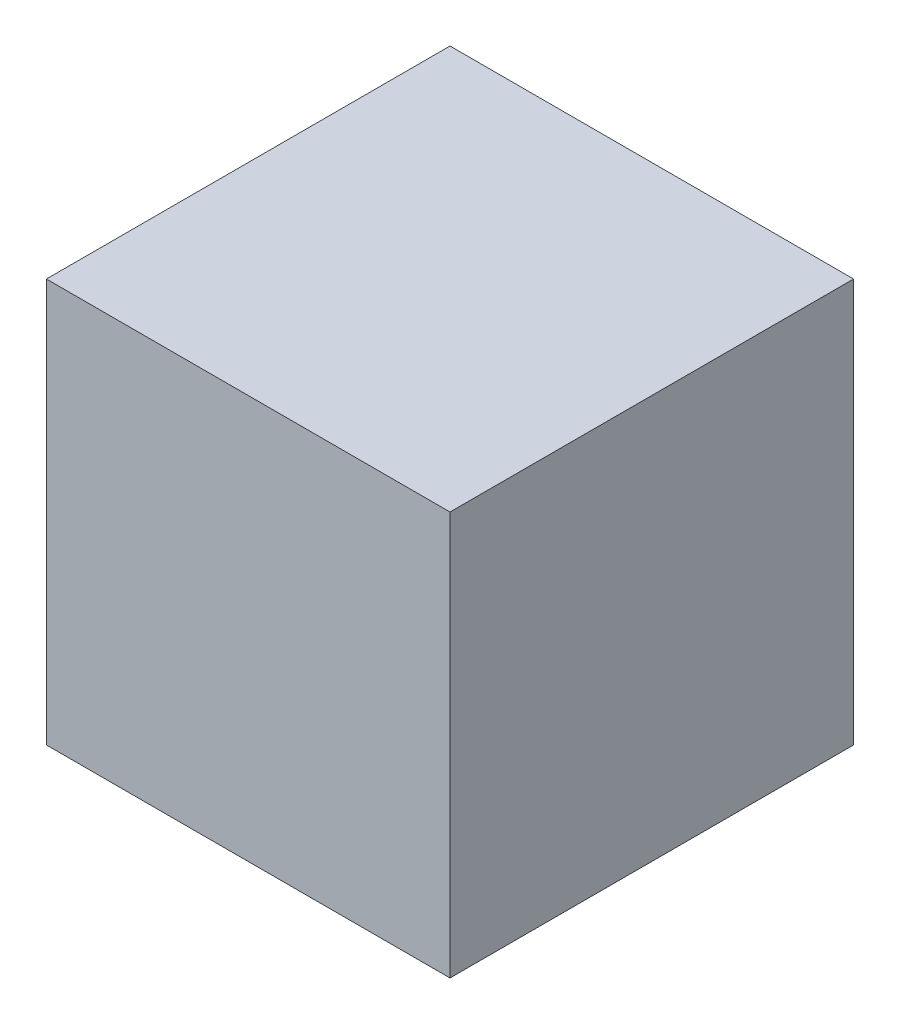
from build123d import *

# Parameters (mm, degrees)
SKETCH1_W           = 50.8
SKETCH1_H           = 50.8
SKETCH1_W_2         = 38.1
SKETCH1_H_2         = 38.1
EXTRUDE_THIN1_DEPTH = 50.8
SKETCH2_W           = 38.1
SKETCH2_H           = 38.108160065
BOSS_EXTRUDE1_DEPTH = 6.35
SKETCH3_W           = 38.1
SKETCH3_H           = 38.108160065
BOSS_EXTRUDE3_DEPTH = 6.35


with BuildPart() as part:
    # Sketch1 → Extrude-Thin1 (new body)
    with BuildSketch(Plane(origin=(0, 0, 0), x_dir=(1, 0, 0), z_dir=(0, 1, 0))):
        with Locations((25.4, 25.4)):
            Rectangle(SKETCH1_W, SKETCH1_H)
        with Locations((25.4, 25.4)):
            Rectangle(SKETCH1_W_2, SKETCH1_H_2, mode=Mode.SUBTRACT)
    extrude(amount=EXTRUDE_THIN1_DEPTH)

    # Sketch2 → Boss-Extrude1 (add)
    with BuildSketch(Plane(origin=(0, 50.8, 0), x_dir=(1, 0, 0), z_dir=(0, 1, 0))):
        with Locations((25.4, 25.404080033)):
            Rectangle(SKETCH2_W, SKETCH2_H)
    extrude(amount=-BOSS_EXTRUDE1_DEPTH)

    # Sketch3 → Boss-Extrude3 (add)
    with BuildSketch(Plane.XZ):
        with Locations((25.4, -25.395919968)):
            Rectangle(SKETCH3_W, SKETCH3_H)
    extrude(amount=-BOSS_EXTRUDE3_DEPTH)


solid = part.part
